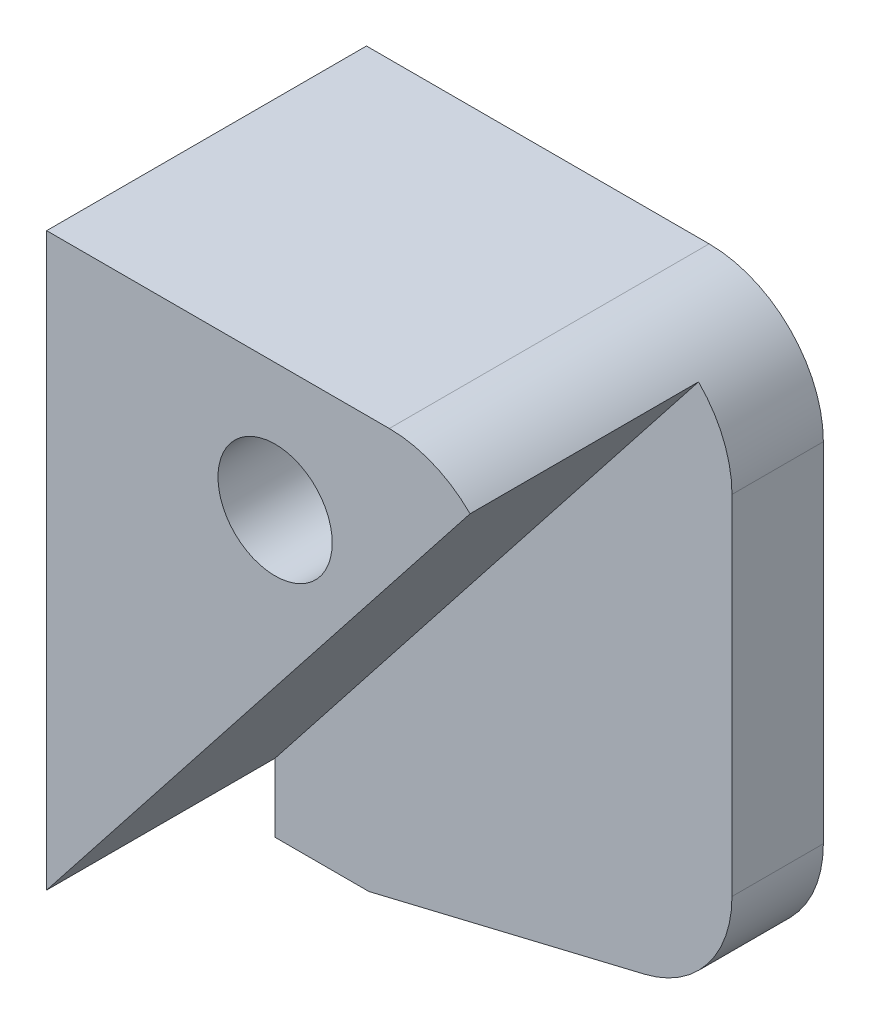
from build123d import *

# Parameters (mm, degrees)
SKETCH_1_R      = 2.5
EXTRUDE_1_DEPTH = 4
FILLET_1_R      = 5
SKETCH_2_R      = 2.5
EXTRUDE_2_DEPTH = 10


with BuildPart() as part:
    # ｽｹｯﾁ1 → ﾎﾞｽ - 押し出し1 (new body)
    with BuildSketch(Plane.XY):
        Polygon((0, 15), (0, 0), (4, 0), (4, -6), (8.110763801, -6), (24, -2.18322685), (24, 22), (4, 22), (4, 15), align=None)
        with Locations((14, 16.41)):
            Circle(SKETCH_1_R, mode=Mode.SUBTRACT)
    extrude(amount=EXTRUDE_1_DEPTH)

    # ﾌｨﾚｯﾄ1
    fillet_1_edges = [part.edges().sort_by_distance(p)[0] for p in [
        (24, 22, 2),
        (24, -2.18322685, 2),
    ]]
    fillet(fillet_1_edges, radius=FILLET_1_R)

    # ｽｹｯﾁ2 → ﾎﾞｽ - 押し出し2 (add)
    with BuildSketch(Plane.XY.offset(4)):
        with BuildLine():
            Line((4, 0), (4, -3))
            Line((4, -3), (22.535533906, 20.535533906))
            ThreePointArc((22.535533906, 20.535533906), (20.913417162, 21.619397663), (19, 22))
            Line((19, 22), (4, 22))
            Line((4, 22), (4, 15))
            Line((4, 15), (4, 0))
        make_face()
        with Locations((14, 16.41)):
            Circle(SKETCH_2_R, mode=Mode.SUBTRACT)
    extrude(amount=EXTRUDE_2_DEPTH)


solid = part.part
